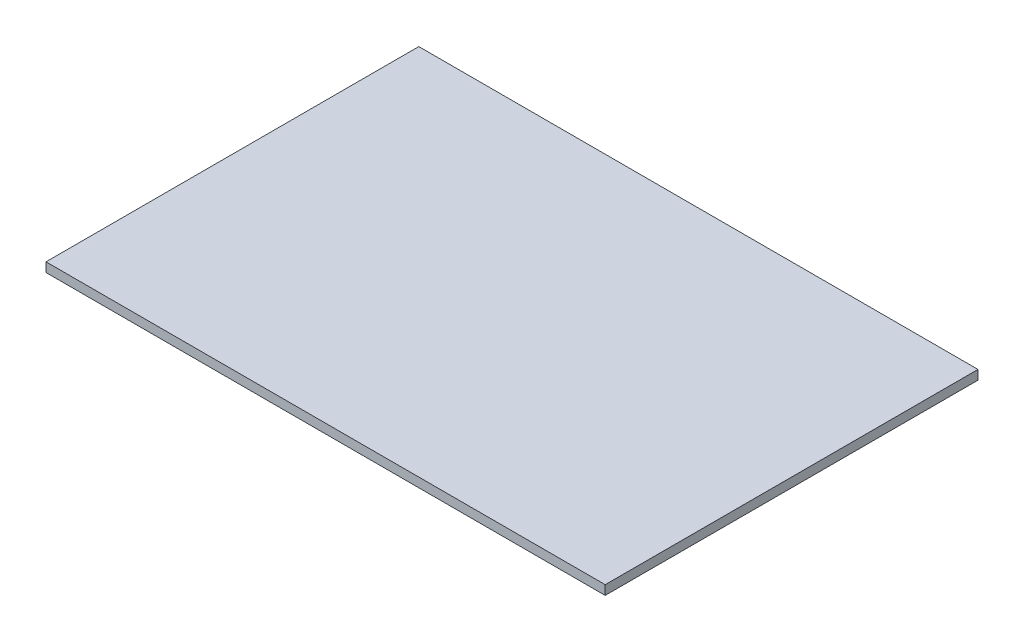
from build123d import *

# Parameters (mm, degrees)
SKETCH1_W        = 60
SKETCH1_H        = 40
EXTRUSION1_DEPTH = 1


with BuildPart() as part:
    # Sketch1 → Extrusion1 (new body)
    with BuildSketch(Plane(origin=(0, 0, 0), x_dir=(-1, 0, 0), z_dir=(0, 1, 0))):
        with Locations((-21.760474068, -15.238751554)):
            Rectangle(SKETCH1_W, SKETCH1_H)
    extrude(amount=EXTRUSION1_DEPTH)


solid = part.part
